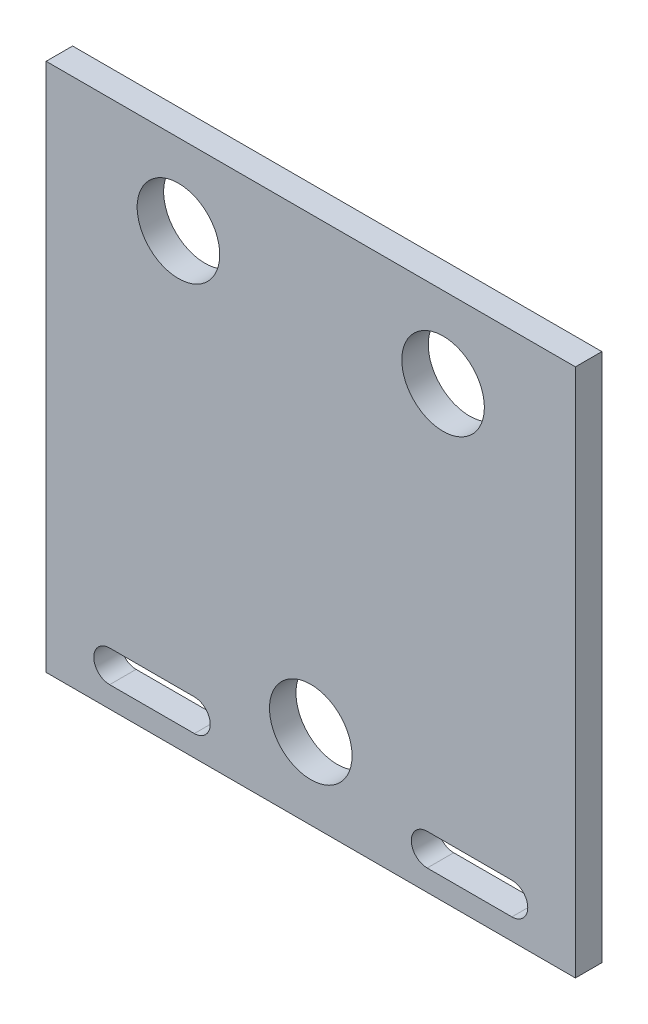
from build123d import *

# Parameters (mm, degrees)
SKETCH1_W           = 63.5
SKETCH1_H           = 63.5
SKETCH1_R           = 4.953
BOSS_EXTRUDE1_DEPTH = 3.175


with BuildPart() as part:
    # Sketch1 → Boss-Extrude1 (new body)
    with BuildSketch(Plane.XY):
        Rectangle(SKETCH1_W, SKETCH1_H)
        with Locations((-15.875, 22.06498)):
            Circle(SKETCH1_R, mode=Mode.SUBTRACT)
        with Locations((15.875, 22.06498)):
            Circle(SKETCH1_R, mode=Mode.SUBTRACT)
        with Locations((0, -22.06498)):
            Circle(SKETCH1_R, mode=Mode.SUBTRACT)
        with BuildLine():
            Line((13.97, -25.4), (24.13, -25.4))
            ThreePointArc((24.13, -25.4), (26.035, -27.305), (24.13, -29.21))
            Line((24.13, -29.21), (13.97, -29.21))
            ThreePointArc((13.97, -29.21), (12.065, -27.305), (13.97, -25.4))
        make_face(mode=Mode.SUBTRACT)
        with BuildLine():
            Line((-13.97, -25.4), (-24.13, -25.4))
            ThreePointArc((-24.13, -25.4), (-26.035, -27.305), (-24.13, -29.21))
            Line((-24.13, -29.21), (-13.97, -29.21))
            ThreePointArc((-13.97, -29.21), (-12.065, -27.305), (-13.97, -25.4))
        make_face(mode=Mode.SUBTRACT)
    extrude(amount=BOSS_EXTRUDE1_DEPTH)


solid = part.part
